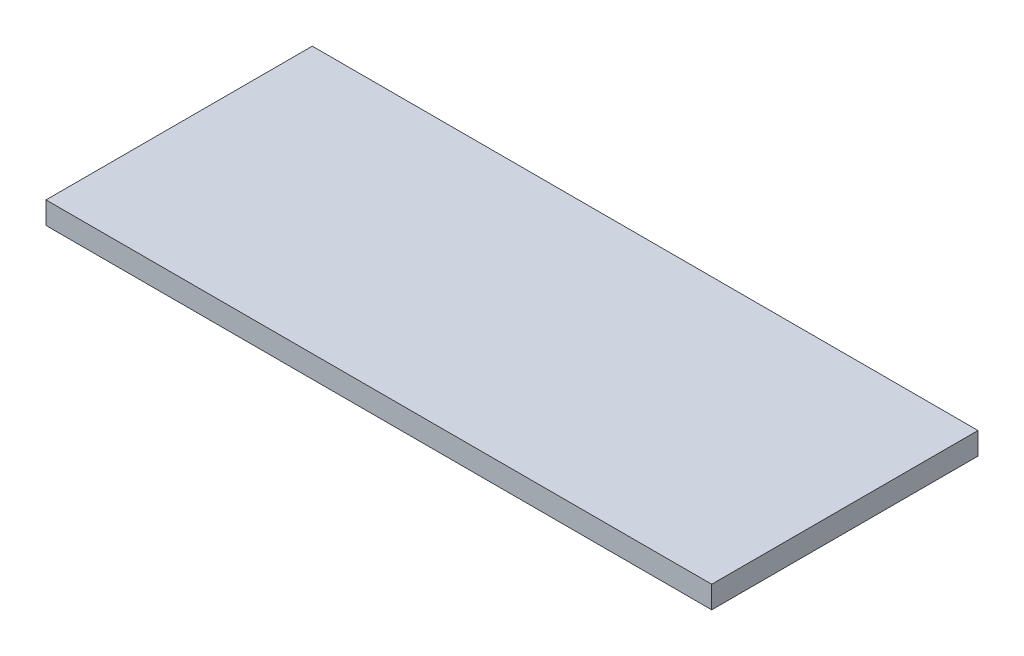
from build123d import *

# Parameters (mm, degrees)
SZKIC1_W                    = 3000
SZKIC1_H                    = 1200
DODANIE_WYCI_GNI_CIE1_DEPTH = 100


with BuildPart() as part:
    # Szkic1 → Dodanie-wyciągnięcie1 (new body)
    with BuildSketch(Plane(origin=(0, 0, 0), x_dir=(1, 0, 0), z_dir=(0, 1, 0))):
        Rectangle(SZKIC1_W, SZKIC1_H)
    extrude(amount=DODANIE_WYCI_GNI_CIE1_DEPTH)


solid = part.part
